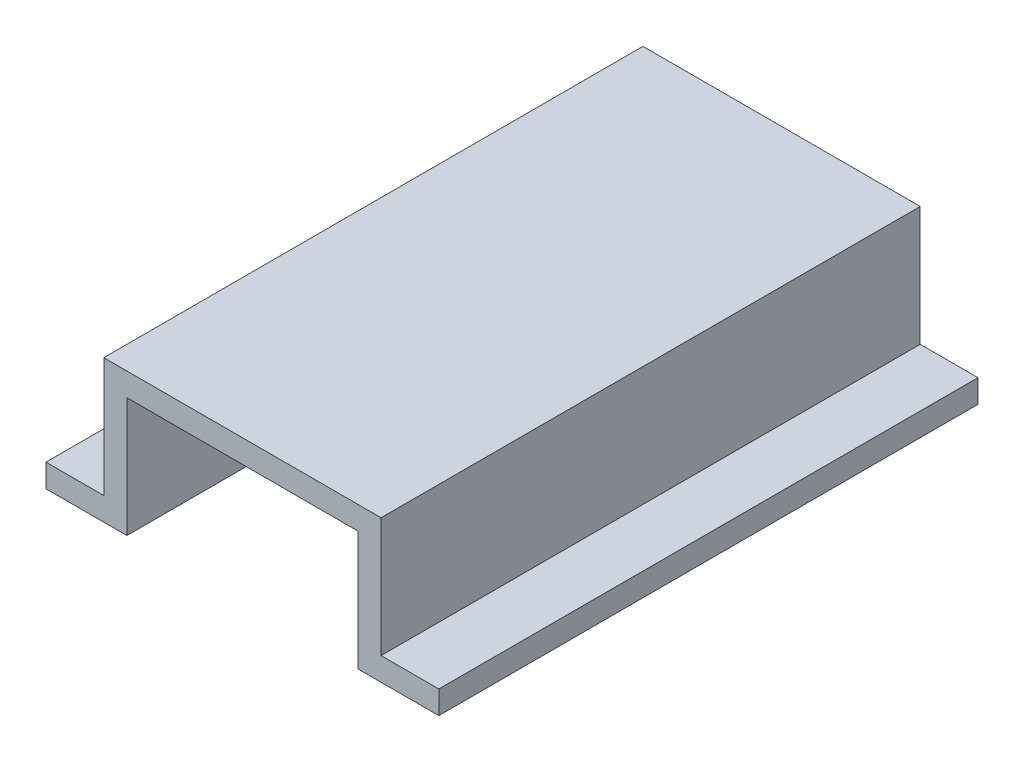
from build123d import *

# Parameters (mm, degrees)
BOSS_EXTRUDE1_DEPTH = 140


with BuildPart() as part:
    # Sketch1 → Boss-Extrude1 (new body)
    with BuildSketch(Plane.XY):
        Polygon((0, 0), (15, 0), (15, 31), (87, 31), (87, 0), (102, 0), (102, -6), (81, -6), (81, 25), (21, 25), (21, -6), (0, -6), align=None)
    extrude(amount=BOSS_EXTRUDE1_DEPTH)


solid = part.part
